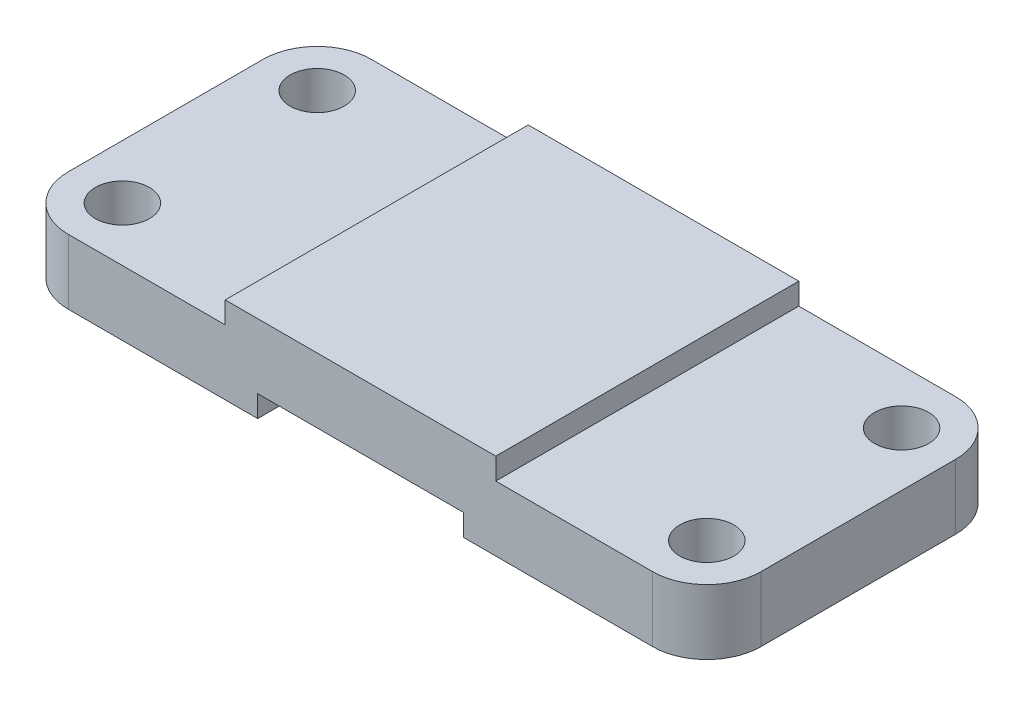
from build123d import *

# Parameters (mm, degrees)
IZIM1_W                     = 50
IZIM1_H                     = 56
Y_KSEKLIK_EKSTR_ZYON1_DEPTH = 16
IZIM1_3_W                   = 39
IZIM1_3_H                   = 56
Y_KSEKLIK_EKSTR_ZYON2_DEPTH = 12
RADYUS1_R                   = 10
IZIM2_R                     = 5
KES_EKSTR_ZYON1_DEPTH       = 106.834776893
IZIM3_R                     = 5
KES_EKSTR_ZYON2_DEPTH       = 106.834776893
IZIM4_W                     = 38
IZIM4_H                     = 4
KES_EKSTR_ZYON4_DEPTH       = 107.362587407


with BuildPart() as part:
    # Çizim1 → Yükseklik-Ekstrüzyon1 (new body)
    with BuildSketch(Plane(origin=(0, 0, 0), x_dir=(1, 0, 0), z_dir=(0, 1, 0))):
        with Locations((-25, 28)):
            Rectangle(IZIM1_W, IZIM1_H)
    extrude(amount=Y_KSEKLIK_EKSTR_ZYON1_DEPTH)

    # Çizim1<3> → Yükseklik-Ekstrüzyon2 (add)
    with BuildSketch(Plane(origin=(0, 0, 0), x_dir=(1, 0, 0), z_dir=(0, 1, 0))):
        with Locations((-69.5, 28)):
            Rectangle(IZIM1_3_W, IZIM1_3_H)
        with Locations((19.5, 28)):
            Rectangle(IZIM1_3_W, IZIM1_3_H)
    extrude(amount=Y_KSEKLIK_EKSTR_ZYON2_DEPTH)

    # Radyus1
    radyus1_edges = [part.edges().sort_by_distance(p)[0] for p in [
        (39, 6, 0),
        (39, 6, -56),
        (-89, 6, -56),
        (-89, 6, 0),
    ]]
    fillet(radyus1_edges, radius=RADYUS1_R)

    # Çizim2 → Kes-Ekstrüzyon1 (cut, through all)
    with BuildSketch(Plane(origin=(0, 12, 0), x_dir=(1, 0, 0), z_dir=(0, 1, 0))):
        with Locations((-79, 46)):
            Circle(IZIM2_R)
        with Locations((-79, 10)):
            Circle(IZIM2_R)
    extrude(amount=-KES_EKSTR_ZYON1_DEPTH, mode=Mode.SUBTRACT)

    # Çizim3 → Kes-Ekstrüzyon2 (cut, through all)
    with BuildSketch(Plane(origin=(0, 12, 0), x_dir=(1, 0, 0), z_dir=(0, 1, 0))):
        with Locations((29, 46)):
            Circle(IZIM3_R)
        with Locations((29, 10)):
            Circle(IZIM3_R)
    extrude(amount=-KES_EKSTR_ZYON2_DEPTH, mode=Mode.SUBTRACT)

    # Çizim4 → Kes-Ekstrüzyon4 (cut, through all)
    with BuildSketch(Plane.XY):
        with Locations((-25, 2)):
            Rectangle(IZIM4_W, IZIM4_H)
    extrude(amount=-KES_EKSTR_ZYON4_DEPTH, mode=Mode.SUBTRACT)


solid = part.part
